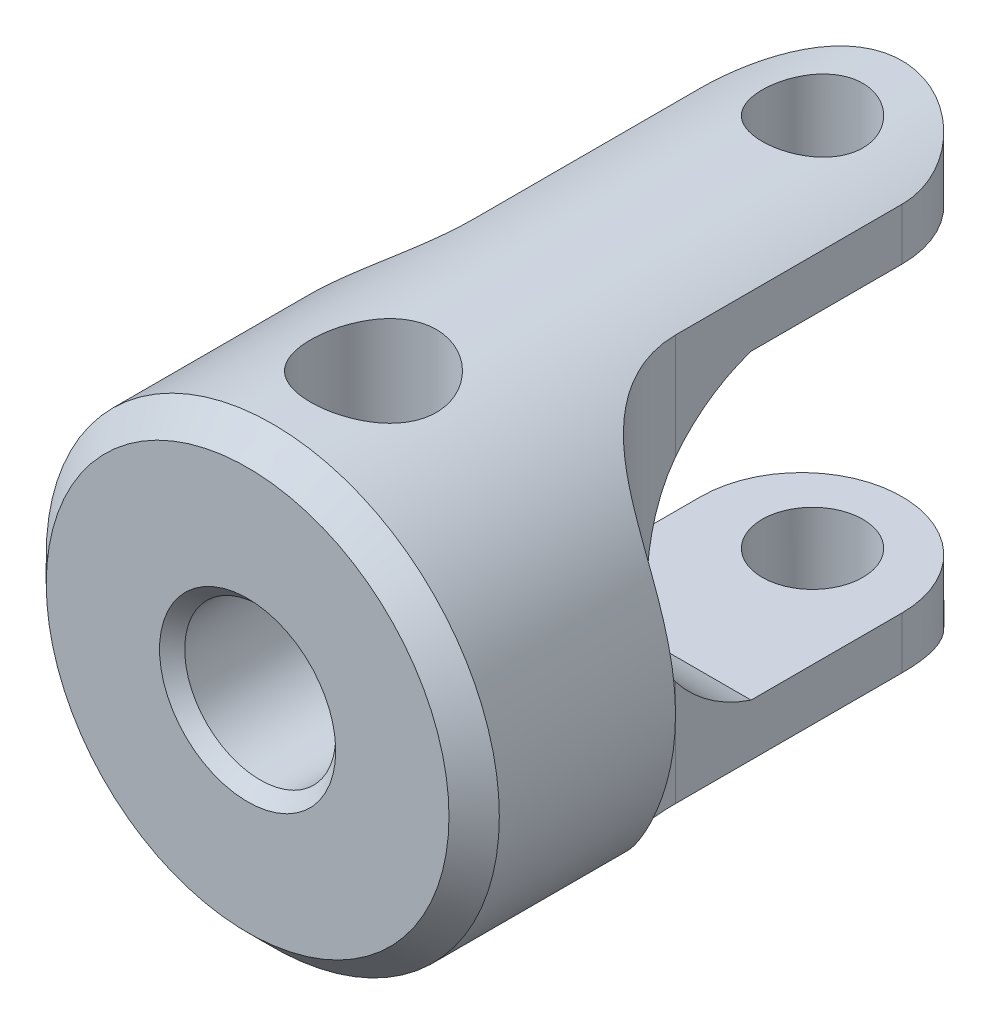
from build123d import *

# Parameters (mm, degrees)
SKETCH_1_R                = 4.5
EXTRUDE_1_DEPTH           = 13
CUT_EXTRUDE_1_DEPTH       = 6.5
CUT_EXTRUDE_2_DEPTH       = 6.5
SKETCH_4_R                = 1
CUT_EXTRUDE_3_DEPTH       = 6.5
HOLE_WIZARD_1_D           = 3
HOLE_WIZARD_1_CSINK_D     = 3.5
HOLE_WIZARD_1_CSINK_ANGLE = 90
CHAMFER_1_SIZE            = 0.5
HOLE_WIZARD_M3_1_REACH    = 18.439
HOLE_WIZARD_M3_1_BORE_R   = 1.25


with BuildPart() as part:
    # 草图1 → 凸台-拉伸1 (new body)
    with BuildSketch(Plane.XY):
        with Locations(Location((0, 0, 0), (0, 0, 180))):
            Circle(SKETCH_1_R)
    extrude(amount=EXTRUDE_1_DEPTH)

    # 草图2 → 切除-拉伸1 (cut, symmetric)
    with BuildSketch(Plane(origin=(0, 0, 0), x_dir=(1, 0, 0), z_dir=(0, 1, 0))):
        with BuildLine():
            Line((5e-09, 0), (-4.5, 0))
            Line((-4.5, 0), (-4.5, -9))
            ThreePointArc((-4.5, -9), (-2.732233047, -8.267766953), (-2, -6.5))
            Line((-2, -6.5), (-2, -2))
            ThreePointArc((-2, -2), (-1.414213561, -0.585786436), (5e-09, 0))
        make_face()
        with BuildLine():
            Line((4.5, 0), (5e-09, 0))
            ThreePointArc((5e-09, 0), (1.414213564, -0.585786439), (2, -2))
            Line((2, -2), (2, -6.5))
            ThreePointArc((2, -6.5), (2.732233047, -8.267766953), (4.5, -9))
            Line((4.5, -9), (4.5, 0))
        make_face()
    extrude(amount=CUT_EXTRUDE_1_DEPTH, both=True, mode=Mode.SUBTRACT)

    # 草图3 → 切除-拉伸2 (cut, symmetric)
    with BuildSketch(Plane(origin=(0, 0, 0), x_dir=(0, 0, -1), z_dir=(1, 0, 0))):
        with BuildLine():
            Line((0, 3), (-5, 3))
            ThreePointArc((-5, 3), (-7.16227766, 0), (-5, -3))
            Line((-5, -3), (0, -3))
            Line((0, -3), (0, 3))
        make_face()
    extrude(amount=CUT_EXTRUDE_2_DEPTH, both=True, mode=Mode.SUBTRACT)

    # 草图4 → 切除-拉伸3 (cut, symmetric)
    with BuildSketch(Plane(origin=(0, 0, 0), x_dir=(1, 0, 0), z_dir=(0, 1, 0))):
        with Locations(Location((0, -1.778928225, 0), (0, 0, 270))):
            Circle(SKETCH_4_R)
    extrude(amount=CUT_EXTRUDE_3_DEPTH, both=True, mode=Mode.SUBTRACT)

    # 打孔尺寸根据开槽半沉头木螺钉的类型1 (through all)
    with Locations(Plane.XY.offset(13)):
        with Locations((0, 0)):
            CounterSinkHole(HOLE_WIZARD_1_D / 2, HOLE_WIZARD_1_CSINK_D / 2, counter_sink_angle=HOLE_WIZARD_1_CSINK_ANGLE)

    # 倒角1
    chamfer_1_edges = [part.edges().sort_by_distance(p)[0] for p in [
        (4.5, 0, 13),
    ]]
    chamfer(chamfer_1_edges, length=CHAMFER_1_SIZE)

    # M3 螺纹孔1 bore → M3 螺纹孔1 (cut, up to next)
    with BuildSketch(Plane(origin=(0, 4.5, 0), x_dir=(1, 0, 0), z_dir=(0, 1, 0)), mode=Mode.PRIVATE) as hole_wizard_m3_1_sk1:
        with Locations((0, -10.5)):
            Circle(HOLE_WIZARD_M3_1_BORE_R)
    hole_wizard_m3_1_tool1 = extrude(hole_wizard_m3_1_sk1.sketch, amount=-HOLE_WIZARD_M3_1_REACH, mode=Mode.PRIVATE) & part.part
    add(hole_wizard_m3_1_tool1.solids().sort_by_distance((0, 4.5, 10.5))[0], mode=Mode.SUBTRACT)


solid = part.part
